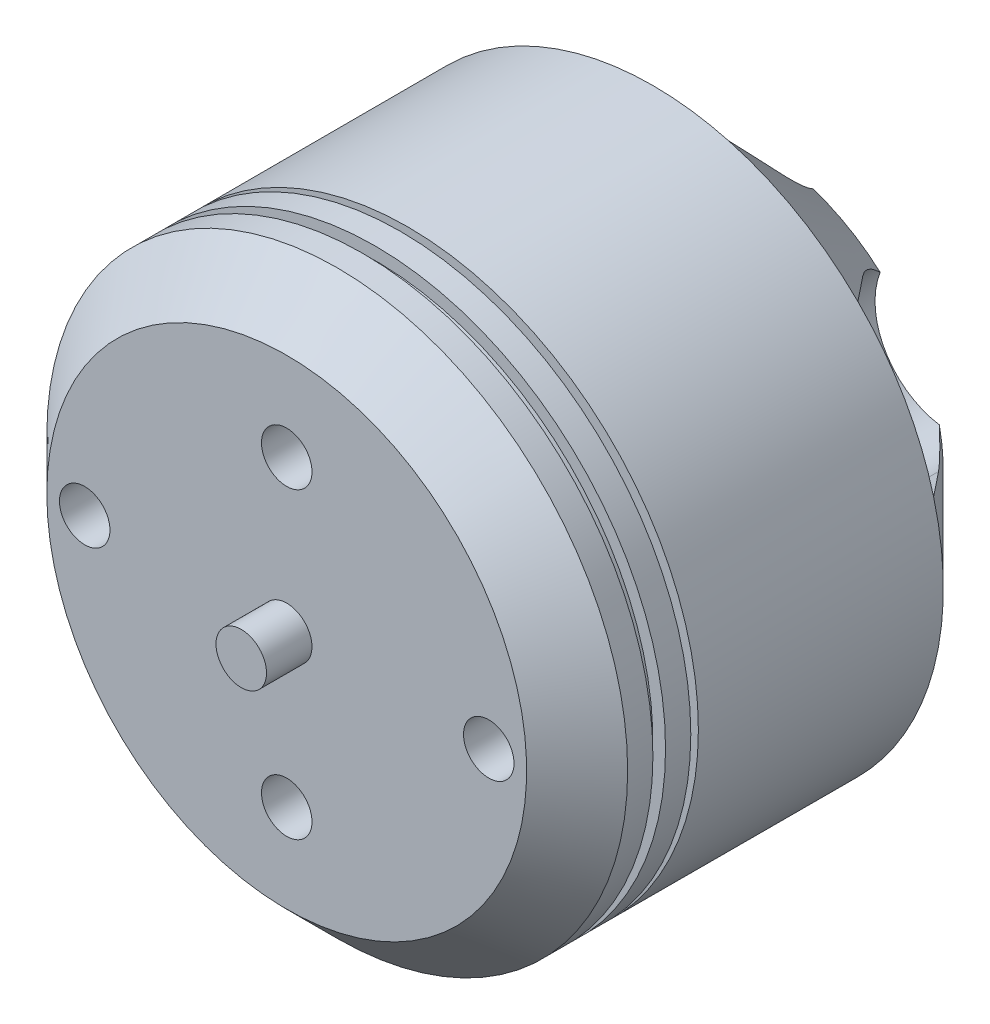
from build123d import *

# Parameters (mm, degrees)
SKETCH3_R          = 1
CUT_EXTRUDE1_DEPTH = 4
SKETCH4_R          = 1
CUT_EXTRUDE2_DEPTH = 3


with BuildPart() as part:
    # Sketch2 → Revolve3 (revolve)
    with BuildSketch(Plane(origin=(0, 0, 0), x_dir=(1, 0, 0), z_dir=(0, 1, 0))):
        Polygon((0, 22), (0, -1.8), (1, -1.8), (1, 0), (9.5, 0), (11.5, 2), (11.5, 3), (11, 3), (11, 3.5), (11.5, 3.5), (11.5, 4.5), (9.5, 4.5), (9.5, 4.8), (11.5, 4.8), (11.5, 14.5), (7.5, 18.5), (1, 18.5), (1, 22), align=None)
        Polygon((2, 17.5), (7.085786438, 17.5), (10.5, 14.085786438), (10.5, 8.994124711), (1, 8.994124711), (1, 16.5), (2, 16.5), align=None, mode=Mode.SUBTRACT)
    revolve(axis=Axis((0, 0, -22), (0, 0, 1)))

    # Sketch3 → Cut-Extrude1 (cut)
    with BuildSketch(Plane(origin=(0, 0, -18.5), x_dir=(-1, 0, 0), z_dir=(0, 0, -1))):
        with Locations((0, 4.5)):
            Circle(SKETCH3_R)
        with Locations((4.5, 0)):
            Circle(SKETCH3_R)
        with Locations((0, -4.5)):
            Circle(SKETCH3_R)
        with Locations((-4.5, 0)):
            Circle(SKETCH3_R)
        with BuildLine():
            Line((-3, 9), (-3, 16.381316394))
            Line((-3, 16.381316394), (3, 16.381316394))
            Line((3, 16.381316394), (3, 9))
            ThreePointArc((3, 9), (0, 6), (-3, 9))
        make_face()
        with BuildLine():
            Line((15.686636144, 5.592581985), (9.294228634, 1.901923789))
            ThreePointArc((9.294228634, 1.901923789), (5.196152423, 3), (6.294228634, 7.098076211))
            Line((6.294228634, 7.098076211), (12.686636144, 10.788734408))
            Line((12.686636144, 10.788734408), (15.686636144, 5.592581985))
        make_face()
        with BuildLine():
            Line((12.686636144, -10.788734408), (6.294228634, -7.098076211))
            ThreePointArc((6.294228634, -7.098076211), (5.196152423, -3), (9.294228634, -1.901923789))
            Line((9.294228634, -1.901923789), (15.686636144, -5.592581985))
            Line((15.686636144, -5.592581985), (12.686636144, -10.788734408))
        make_face()
        with BuildLine():
            Line((-3, -16.381316394), (-3, -9))
            ThreePointArc((-3, -9), (0, -6), (3, -9))
            Line((3, -9), (3, -16.381316394))
            Line((3, -16.381316394), (-3, -16.381316394))
        make_face()
        with BuildLine():
            Line((-15.686636144, -5.592581985), (-9.294228634, -1.901923789))
            ThreePointArc((-9.294228634, -1.901923789), (-5.196152423, -3), (-6.294228634, -7.098076211))
            Line((-6.294228634, -7.098076211), (-12.686636144, -10.788734408))
            Line((-12.686636144, -10.788734408), (-15.686636144, -5.592581985))
        make_face()
        with BuildLine():
            Line((-12.686636144, 10.788734408), (-6.294228634, 7.098076211))
            ThreePointArc((-6.294228634, 7.098076211), (-5.196152423, 3), (-9.294228634, 1.901923789))
            Line((-9.294228634, 1.901923789), (-15.686636144, 5.592581985))
            Line((-15.686636144, 5.592581985), (-12.686636144, 10.788734408))
        make_face()
    extrude(amount=-CUT_EXTRUDE1_DEPTH, mode=Mode.SUBTRACT)

    # Sketch4 → Cut-Extrude2 (cut)
    with BuildSketch(Plane.XY):
        with Locations((0, 6)):
            Circle(SKETCH4_R)
        with Locations((0, -6)):
            Circle(SKETCH4_R)
        with Locations((8, 0)):
            Circle(SKETCH4_R)
        with Locations((-8, 0)):
            Circle(SKETCH4_R)
    extrude(amount=-CUT_EXTRUDE2_DEPTH, mode=Mode.SUBTRACT)


solid = part.part
